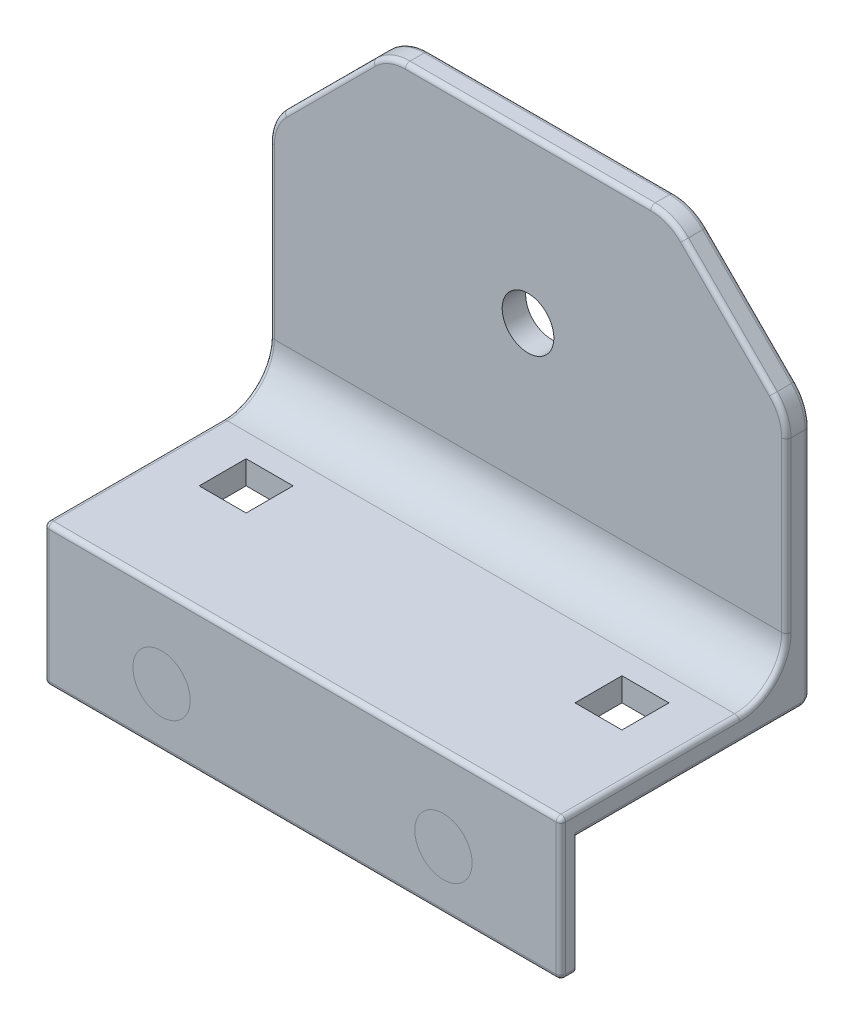
from build123d import *

# Parameters (mm, degrees)
SKETCH1_W             = 110
SKETCH1_H             = 50
SKETCH1_W_2           = 10
SKETCH1_H_2           = 10
BOSS_EXTRUDE1_DEPTH   = 5
SKETCH2_R             = 6.1
SKETCH2_W             = 110
SKETCH2_H             = 5
BOSS_EXTRUDE2_DEPTH   = 3
SKETCH3_R             = 5.5
BOSS_EXTRUDE3_DEPTH   = 5
FILLET1_R             = 10
FILLET2_R             = 10
FILLET3_R             = 2
FILLET4_R             = 1
FILLET5_R             = 1
SKETCH4_R             = 6.1
BOSS_EXTRUDE4_DEPTH   = 3
BOSS_EXTRUDE4_2_DEPTH = 3


with BuildPart() as part:
    # Sketch1 → Boss-Extrude1 (new body)
    with BuildSketch(Plane(origin=(0, 0, 0), x_dir=(1, 0, 0), z_dir=(0, 1, 0))):
        with Locations((55, 25)):
            Rectangle(SKETCH1_W, SKETCH1_H)
        with Locations((15, 25)):
            Rectangle(SKETCH1_W_2, SKETCH1_H_2, mode=Mode.SUBTRACT)
        with Locations((95, 25)):
            Rectangle(SKETCH1_W_2, SKETCH1_H_2, mode=Mode.SUBTRACT)
    extrude(amount=BOSS_EXTRUDE1_DEPTH)

    # Sketch2 → Boss-Extrude2 (add)
    with BuildSketch(Plane.XY):
        Polygon((0, 0), (0, -25), (25, -25), (85, -25), (110, -25), (110, 0), align=None)
        with Locations((25, -12.5)):
            Circle(SKETCH2_R, mode=Mode.SUBTRACT)
        with Locations((85, -12.5)):
            Circle(SKETCH2_R, mode=Mode.SUBTRACT)
        with Locations((55, 2.5)):
            Rectangle(SKETCH2_W, SKETCH2_H)
    extrude(amount=BOSS_EXTRUDE2_DEPTH)

    # Sketch3 → Boss-Extrude3 (add)
    with BuildSketch(Plane(origin=(0, 0, -50), x_dir=(-1, 0, 0), z_dir=(0, 0, -1))):
        Polygon((-110, 5), (0, 5), (0, 55), (-24.748737342, 79.748737342), (-85.251262658, 79.748737342), (-110, 55), align=None)
        with Locations((-55, 45)):
            Circle(SKETCH3_R, mode=Mode.SUBTRACT)
    extrude(amount=-BOSS_EXTRUDE3_DEPTH)

    # Fillet1
    fillet1_edges = [part.edges().sort_by_distance(p)[0] for p in [
        (0, 55, -47.5),
        (110, 55, -47.5),
        (85.251262658, 79.748737342, -47.5),
        (24.748737342, 79.748737342, -47.5),
    ]]
    fillet(fillet1_edges, radius=FILLET1_R)

    # Fillet2
    fillet2_edges = [part.edges().sort_by_distance(p)[0] for p in [
        (55, 5, -45),
    ]]
    fillet(fillet2_edges, radius=FILLET2_R)

    # Fillet3
    fillet3_edges = [part.edges().sort_by_distance(p)[0] for p in [
        (55, 0, -50),
    ]]
    fillet(fillet3_edges, radius=FILLET3_R)

    # Fillet4
    fillet4_edges = [part.edges().sort_by_distance(p)[0] for p in [
        (0, 32.928932188, -45),
        (0, 5, -16),
        (110, 7.928932188, -42.071067812),
        (0, 7.928932188, -42.071067812),
        (0, 0, -24),
        (0, 0.585786438, -49.414213562),
        (110, 0.585786438, -49.414213562),
        (110, 5, -16),
        (110, 0, -24),
        (55, 79.748737342, -50),
        (55, 79.748737342, -45),
        (0, 26.428932188, -50),
        (12.374368671, 67.374368671, -50),
        (97.625631329, 67.374368671, -50),
        (110, 26.428932188, -50),
        (25.064038642, 78.987532667, -50),
        (0.761204675, 54.6846987, -50),
        (109.238795325, 54.6846987, -50),
        (84.935961358, 78.987532667, -50),
        (97.625631329, 67.374368671, -45),
        (110, 32.928932188, -45),
        (12.374368671, 67.374368671, -45),
        (25.064038642, 78.987532667, -45),
        (0.761204675, 54.6846987, -45),
        (109.238795325, 54.6846987, -45),
        (84.935961358, 78.987532667, -45),
    ]]
    fillet(fillet4_edges, radius=FILLET4_R)

    # Fillet5
    fillet5_edges = [part.edges().sort_by_distance(p)[0] for p in [
        (110, -10.5, 3),
        (0, -10.5, 3),
        (55, 5, 3),
        (0.292893219, 4.707106781, 3),
        (109.707106781, 4.707106781, 3),
        (110, -25, 1.5),
        (55, -25, 0),
        (0, -25, 1.5),
        (55, -25, 3),
    ]]
    fillet(fillet5_edges, radius=FILLET5_R)


with BuildPart() as body_2:
    # Sketch4 → Boss-Extrude4 (new body)
    with BuildSketch(Plane.XY.offset(3)):
        with Locations((25, -12.5)):
            Circle(SKETCH4_R)
    extrude(amount=-BOSS_EXTRUDE4_DEPTH)


with BuildPart() as body_3:
    # Sketch4 → Boss-Extrude4 2 (new body)
    with BuildSketch(Plane.XY.offset(3)):
        with Locations((85, -12.5)):
            Circle(SKETCH4_R)
    extrude(amount=-BOSS_EXTRUDE4_2_DEPTH)


solid = Compound([part.part, body_2.part, body_3.part])
